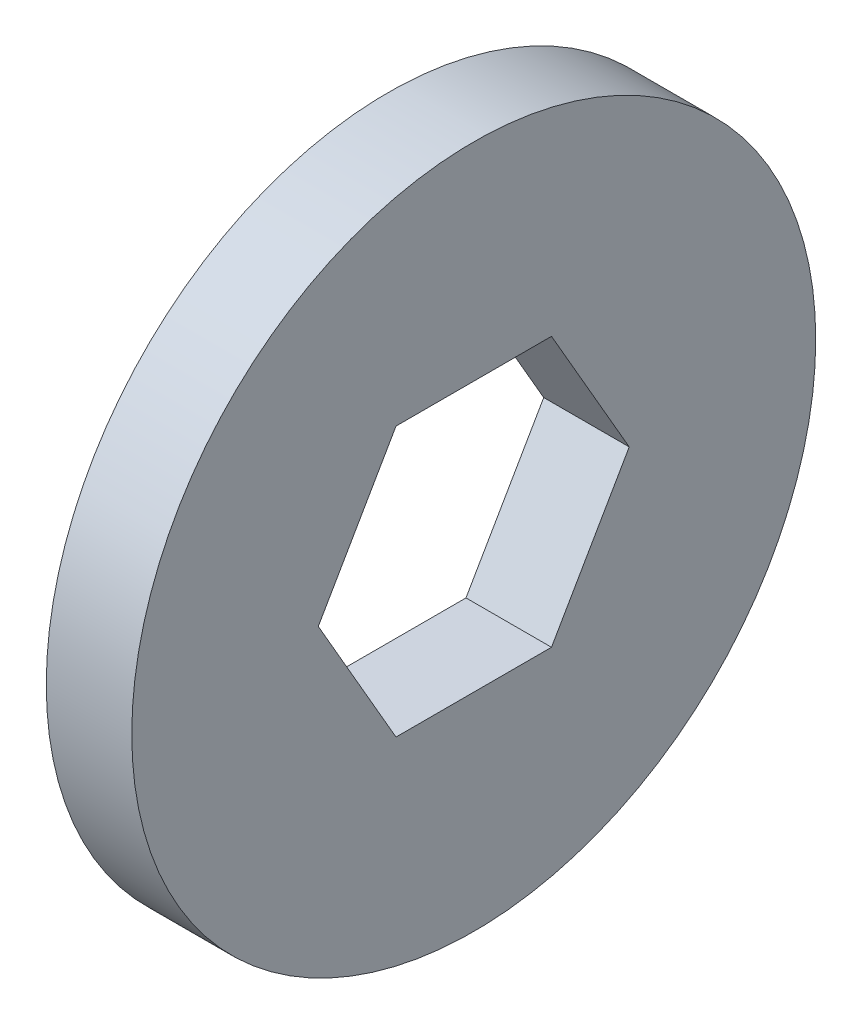
from build123d import *

# Parameters (mm, degrees)
SKETCH1_R           = 6.35
BOSS_EXTRUDE1_DEPTH = 1.5875


with BuildPart() as part:
    # Sketch1 → Boss-Extrude1 (new body)
    with BuildSketch(Plane(origin=(0, 0, 0), x_dir=(0, 0, -1), z_dir=(1, 0, 0))):
        Circle(SKETCH1_R)
        Polygon((2.886751346, 0), (1.443375673, 2.5), (-1.443375673, 2.5), (-2.886751346, 0), (-1.443375673, -2.5), (1.443375673, -2.5), align=None, mode=Mode.SUBTRACT)
    extrude(amount=BOSS_EXTRUDE1_DEPTH)


solid = part.part
